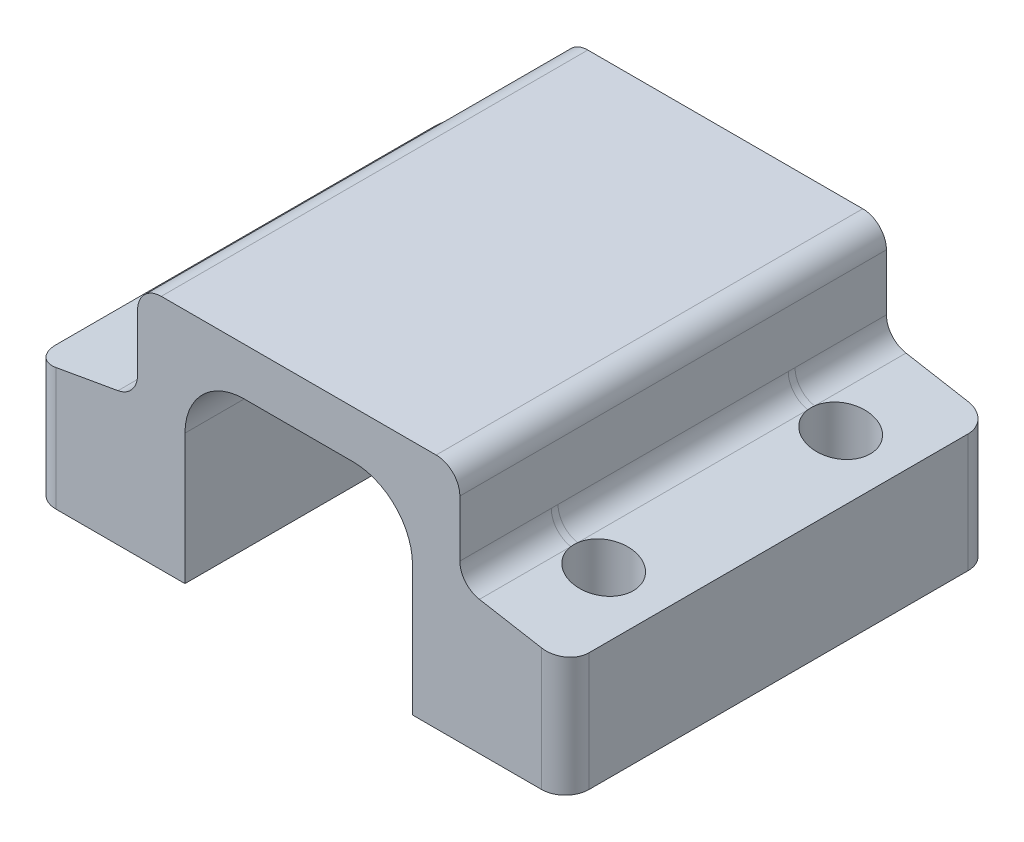
from build123d import *

# Parameters (mm, degrees)
BOSS_EXTRUDE1_DEPTH = 22.86
BOSS_EXTRUDE2_DEPTH = 13.462
BOSS_EXTRUDE3_START = -1.27
BOSS_EXTRUDE3_DEPTH = 1.905
BOSS_EXTRUDE4_START = -1.27
BOSS_EXTRUDE4_DEPTH = 3.81
FILLET1_R           = 1.27


with BuildPart() as part:
    # Sketch1 → Boss-Extrude1 (new body)
    with BuildSketch(Plane.XY):
        Polygon((-6.096, 10.16), (6.096, 10.16), (6.096, 0), (14.2875, 0), (14.2875, 6.35), (8.636, 7.346511931), (8.636, 12.7), (-8.636, 12.7), (-8.636, 7.346511931), (-14.2875, 6.35), (-14.2875, 0), (-6.096, 0), align=None)
    extrude(amount=-BOSS_EXTRUDE1_DEPTH)

    # Sketch2 → Boss-Extrude2 (add)
    with BuildSketch(Plane.XY):
        with BuildLine():
            Line((2.921, 10.16), (6.096, 10.16))
            Line((6.096, 10.16), (6.096, 6.985))
            ThreePointArc((6.096, 6.985), (5.16606403, 9.23006403), (2.921, 10.16))
        make_face()
        with BuildLine():
            Line((-6.096, 10.16), (-6.096, 6.985))
            ThreePointArc((-6.096, 6.985), (-5.16606403, 9.23006403), (-2.921, 10.16))
            Line((-2.921, 10.16), (-6.096, 10.16))
        make_face()
    extrude(amount=-BOSS_EXTRUDE2_DEPTH)

    # Sketch3 → Boss-Extrude3 (add)
    with BuildSketch(Plane.XY.offset(-13.462).offset(BOSS_EXTRUDE3_START)):
        with BuildLine():
            Line((-6.096, 10.16), (-6.096, 6.985))
            ThreePointArc((-6.096, 6.985), (-5.16606403, 9.23006403), (-2.921, 10.16))
            Line((-2.921, 10.16), (-6.096, 10.16))
        make_face()
    extrude(amount=-BOSS_EXTRUDE3_DEPTH)

    # Sketch4 → Boss-Extrude4 (add)
    with BuildSketch(Plane.XY.offset(-16.637).offset(BOSS_EXTRUDE4_START)):
        with BuildLine():
            Line((-6.096, 10.16), (-6.096, 6.985))
            ThreePointArc((-6.096, 6.985), (-5.16606403, 9.23006403), (-2.921, 10.16))
            Line((-2.921, 10.16), (-6.096, 10.16))
        make_face()
    extrude(amount=-BOSS_EXTRUDE4_DEPTH)

    # Sketch6 → Cut-Revolve1 (revolve, cut)
    with BuildSketch(Plane.XY.offset(-5.08)):
        Polygon((11.262482277, -1.27), (12.849982277, -1.27), (12.849982277, 6.60347316), (12.849982277, 9.423392242), (11.262482277, 9.423392242), (11.262482277, 6.883392242), align=None)
    cut_revolve1 = revolve(axis=Axis((11.262482277, -1.27, -5.08), (0, -1, 0)), mode=Mode.SUBTRACT)

    # Mirror1: Cut-Revolve1 across plane
    add(cut_revolve1.mirror(Plane(origin=(0, 0, 0), x_dir=(0, 0, 1), z_dir=(1, 0, 0))), mode=Mode.SUBTRACT)

    # Mirror2: Cut-Revolve1 across plane
    add(cut_revolve1.mirror(Plane.XY.offset(-11.43)), mode=Mode.SUBTRACT)

    # Mirror2 copy 1 sketch → Mirror2 copy 1 (revolve, cut)
    with BuildSketch(Plane(origin=(0, 0, -17.78), x_dir=(-1, 0, 0), z_dir=(0, 0, -1))):
        Polygon((11.262482277, -1.27), (12.849982277, -1.27), (12.849982277, 6.60347316), (12.849982277, 9.423392242), (11.262482277, 9.423392242), (11.262482277, 6.883392242), align=None)
    revolve(axis=Axis((-11.262482277, -1.27, -17.78), (0, -1, 0)), mode=Mode.SUBTRACT)

    # Fillet1
    fillet1_edges = [part.edges().sort_by_distance(p)[0] for p in [
        (-14.2875, 3.175, 0),
        (14.2875, 3.175, 0),
        (14.2875, 3.175, -22.86),
        (-8.636, 7.346511931, -11.43),
        (-8.636, 12.7, -11.43),
        (8.636, 12.7, -11.43),
        (8.636, 7.346511931, -11.43),
        (-14.2875, 3.175, -22.86),
    ]]
    fillet(fillet1_edges, radius=FILLET1_R)


solid = part.part
